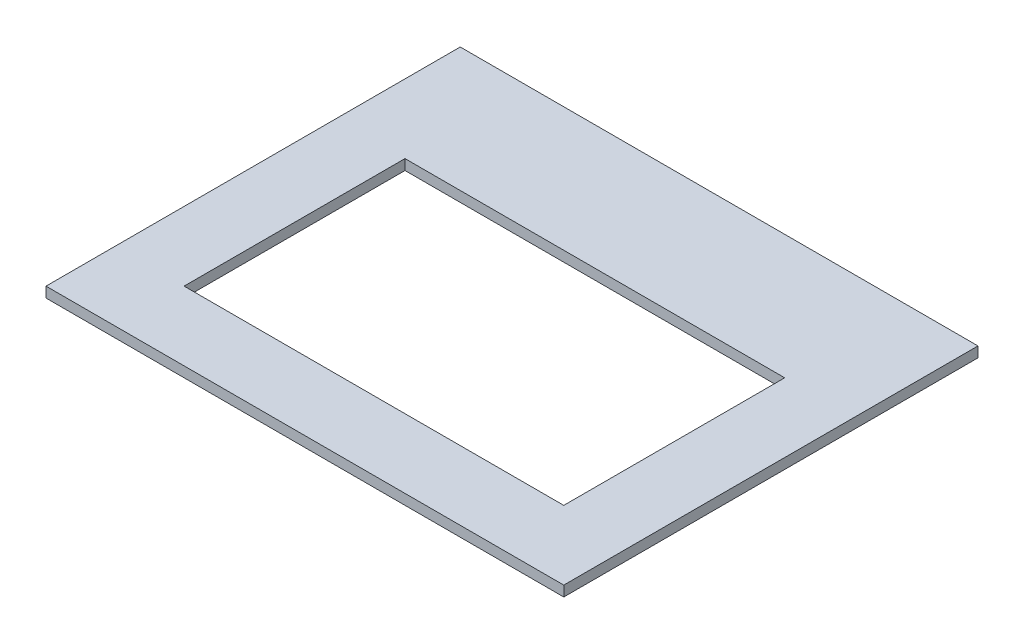
from build123d import *

# Parameters (mm, degrees)
SKETCH_1_W          = 150
SKETCH_1_H          = 120
EXTRUDE_1_DEPTH     = 3
SKETCH_2_W          = 110
SKETCH_2_H          = 64
CUT_EXTRUDE_1_DEPTH = 3


with BuildPart() as part:
    # 草图1 → 凸台-拉伸1 (new body)
    with BuildSketch(Plane(origin=(0, 0, 0), x_dir=(1, 0, 0), z_dir=(0, 1, 0))):
        with Locations((75, -60)):
            Rectangle(SKETCH_1_W, SKETCH_1_H)
    extrude(amount=EXTRUDE_1_DEPTH)

    # 草图2 → 切除-拉伸1 (cut)
    with BuildSketch(Plane.XZ):
        with Locations((75, 68)):
            Rectangle(SKETCH_2_W, SKETCH_2_H)
    extrude(amount=-CUT_EXTRUDE_1_DEPTH, mode=Mode.SUBTRACT)


solid = part.part
